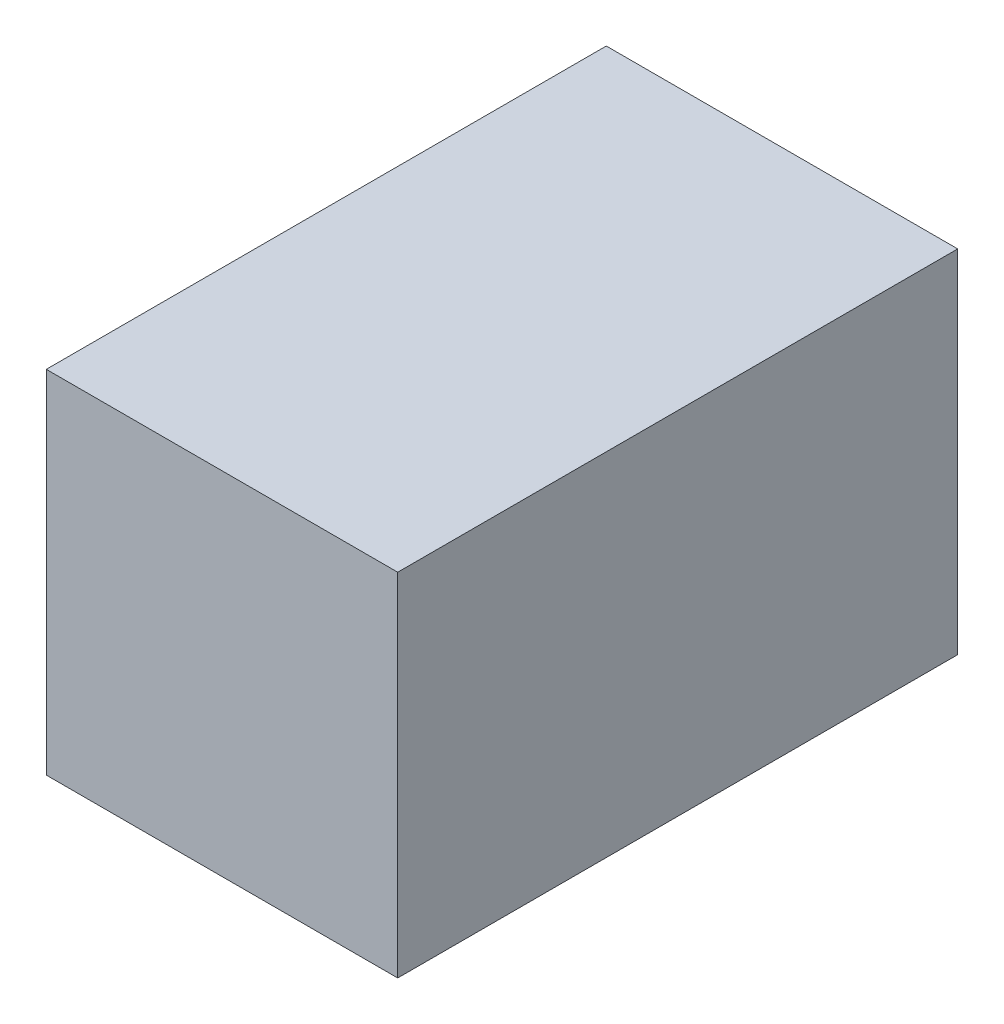
from build123d import *

# Parameters (mm, degrees)
SCHIZZO1_W                   = 100.409162928
SCHIZZO1_H                   = 100.409162928
ESTRUSIONE_ESTRUSIONE1_DEPTH = 160


with BuildPart() as part:
    # Schizzo1 → Estrusione-Estrusione1 (new body)
    with BuildSketch(Plane.XY):
        Rectangle(SCHIZZO1_W, SCHIZZO1_H)
    extrude(amount=ESTRUSIONE_ESTRUSIONE1_DEPTH)


solid = part.part
